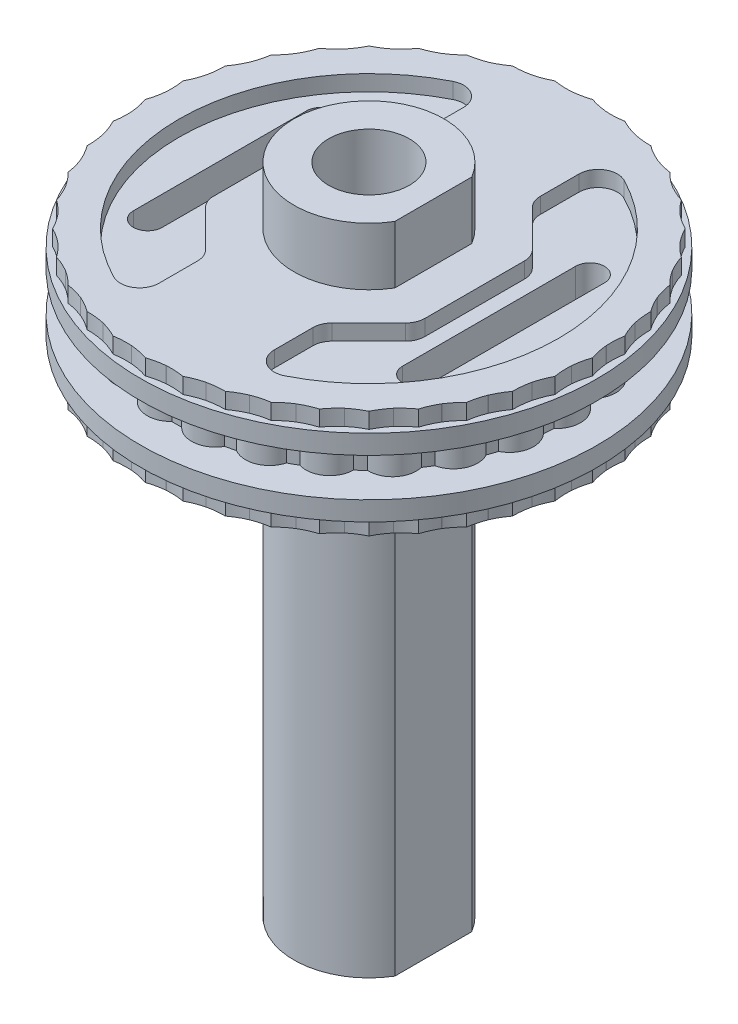
from build123d import *

# Parameters (mm, degrees)
SKETCH1_W                 = 5
SKETCH1_H                 = 1
BOSS_EXTRUDE1_DEPTH       = 1
CIRPATTERN1_COUNT         = 25
BOSS_EXTRUDE2_DEPTH       = 0.4
CIRPATTERN2_COUNT         = 40
MIRROR2_COPY_1_DEPTH      = 0.4
MIRROR2_COPY_2_DEPTH      = 0.4
MIRROR2_COPY_3_DEPTH      = 0.4
MIRROR2_COPY_4_DEPTH      = 0.4
MIRROR2_COPY_5_DEPTH      = 0.4
MIRROR2_COPY_6_DEPTH      = 0.4
MIRROR2_COPY_7_DEPTH      = 0.4
MIRROR2_COPY_8_DEPTH      = 0.4
MIRROR2_COPY_9_DEPTH      = 0.4
MIRROR2_COPY_10_DEPTH     = 0.4
MIRROR2_COPY_11_DEPTH     = 0.4
MIRROR2_COPY_12_DEPTH     = 0.4
MIRROR2_COPY_13_DEPTH     = 0.4
MIRROR2_COPY_14_DEPTH     = 0.4
MIRROR2_COPY_15_DEPTH     = 0.4
MIRROR2_COPY_16_DEPTH     = 0.4
MIRROR2_COPY_17_DEPTH     = 0.4
MIRROR2_COPY_18_DEPTH     = 0.4
MIRROR2_COPY_19_DEPTH     = 0.4
MIRROR2_COPY_20_DEPTH     = 0.4
MIRROR2_COPY_21_DEPTH     = 0.4
MIRROR2_COPY_22_DEPTH     = 0.4
MIRROR2_COPY_23_DEPTH     = 0.4
MIRROR2_COPY_24_DEPTH     = 0.4
MIRROR2_COPY_25_DEPTH     = 0.4
MIRROR2_COPY_26_DEPTH     = 0.4
MIRROR2_COPY_27_DEPTH     = 0.4
MIRROR2_COPY_28_DEPTH     = 0.4
MIRROR2_COPY_29_DEPTH     = 0.4
MIRROR2_COPY_30_DEPTH     = 0.4
MIRROR2_COPY_31_DEPTH     = 0.4
MIRROR2_COPY_32_DEPTH     = 0.4
MIRROR2_COPY_33_DEPTH     = 0.4
MIRROR2_COPY_34_DEPTH     = 0.4
MIRROR2_COPY_35_DEPTH     = 0.4
MIRROR2_COPY_36_DEPTH     = 0.4
MIRROR2_COPY_37_DEPTH     = 0.4
MIRROR2_COPY_38_DEPTH     = 0.4
MIRROR2_COPY_39_DEPTH     = 0.4
BOSS_EXTRUDE4_DEPTH       = 0.01
BOSS_EXTRUDE3_START       = 1.5
BOSS_EXTRUDE3_DEPTH       = 17
CUT_EXTRUDE2_DEPTH        = 17.403157966
CUT_EXTRUDE2_DEPTH_BACK   = 17.403157966
CUT_EXTRUDE3_DEPTH        = 0.41
F_2_0MM_DOWEL_HOLE1_D     = 2.1
F_2_0MM_DOWEL_HOLE1_DEPTH = 7.36909635
F_2_0MM_DOWEL_HOLE1_TIP   = 0.63090365
F_2_0MM_DOWEL_HOLE2_D     = 2.1
F_2_0MM_DOWEL_HOLE2_DEPTH = 7.36909635
F_2_0MM_DOWEL_HOLE2_TIP   = 0.63090365


with BuildPart() as part:
    # Sketch1 → Revolve1 (revolve)
    with BuildSketch(Plane(origin=(0, 0, 0), x_dir=(0, 0, -1), z_dir=(1, 0, 0)), mode=Mode.PRIVATE) as revolve1_sk:
        with Locations((-2.5, 0)):
            Rectangle(SKETCH1_W, SKETCH1_H)
    revolve(revolve1_sk.sketch.rotate(Axis((0, -0.599020678, 0), (0, 1, 0)), 180), axis=Axis((0, -0.599020678, 0), (0, 1, 0)))

    # Sketch2 → Boss-Extrude1 (add)
    with BuildSketch(Plane(origin=(0, 0.5, 0), x_dir=(1, 0, 0), z_dir=(0, 1, 0))):
        with BuildLine():
            ThreePointArc((-0.5, 4.974937186), (0, 5.224937186), (0.5, 4.974937186))
            ThreePointArc((0.5, 4.974937186), (0, 5), (-0.5, 4.974937186))
        make_face()
    boss_extrude1 = extrude(amount=-BOSS_EXTRUDE1_DEPTH)

    # CirPattern1: Boss-Extrude1 ×25 about axis
    cirpattern1_axis = Axis((0, 0, 0), (0, 1, 0))
    for i in range(1, CIRPATTERN1_COUNT):
        add(boss_extrude1.rotate(cirpattern1_axis, i * 360 / CIRPATTERN1_COUNT))

    # Sketch3 → Revolve2 (revolve)
    with BuildSketch(Plane(origin=(0, 0, 0), x_dir=(0, 0, -1), z_dir=(1, 0, 0)), mode=Mode.PRIVATE) as revolve2_sk:
        Polygon((0, 0.5), (-5.938665307, 0.5), (-5.938665307, 1), (-5.738665307, 1), (-5.738665307, 1.4), (0, 1.4), align=None)
    revolve2 = revolve(revolve2_sk.sketch.rotate(Axis((0, 0, 0), (0, 1, 0)), 180), axis=Axis((0, 0, 0), (0, 1, 0)))

    # Sketch4 → Boss-Extrude2 (add)
    with BuildSketch(Plane(origin=(0, 1.4, 0), x_dir=(1, 0, 0), z_dir=(0, 1, 0))):
        with BuildLine():
            Line((0, 5.816841742), (0, 5.738665307))
            ThreePointArc((0, 5.738665307), (0.224059297, 5.734289576), (0.447776903, 5.721169054))
            ThreePointArc((0.447776903, 5.721169054), (0.221141488, 5.756148785), (0, 5.816841742))
        make_face()
        with BuildLine():
            ThreePointArc((-0.447776903, 5.721169054), (-0.224059297, 5.734289576), (0, 5.738665307))
            Line((0, 5.738665307), (0, 5.816841742))
            ThreePointArc((0, 5.816841742), (-0.221141488, 5.756148785), (-0.447776903, 5.721169054))
        make_face()
    boss_extrude2 = extrude(amount=-BOSS_EXTRUDE2_DEPTH)

    # CirPattern2: Boss-Extrude2 ×40 about axis
    cirpattern2_axis = Axis((0, 0, 0), (0, 1, 0))
    for i in range(1, CIRPATTERN2_COUNT):
        add(boss_extrude2.rotate(cirpattern2_axis, i * 360 / CIRPATTERN2_COUNT))

    # Mirror2: Revolve2, Boss-Extrude2 across plane
    add(revolve2.mirror(Plane.ZX))
    add(boss_extrude2.mirror(Plane.ZX))

    # Mirror2 copy 1 sketch → Mirror2 copy 1 (add)
    with BuildSketch(Plane(origin=(0, -1.4, 0), x_dir=(0.9876883405951378, 0, -0.15643446504023087), z_dir=(0, -1, 0))):
        with BuildLine():
            Line((0, -5.816841742), (0, -5.738665307))
            ThreePointArc((0, -5.738665307), (0.224059297, -5.734289576), (0.447776903, -5.721169054))
            ThreePointArc((0.447776903, -5.721169054), (0.221141488, -5.756148785), (0, -5.816841742))
        make_face()
        with BuildLine():
            ThreePointArc((-0.447776903, -5.721169054), (-0.224059297, -5.734289576), (0, -5.738665307))
            Line((0, -5.738665307), (0, -5.816841742))
            ThreePointArc((0, -5.816841742), (-0.221141488, -5.756148785), (-0.447776903, -5.721169054))
        make_face()
    extrude(amount=-MIRROR2_COPY_1_DEPTH)

    # Mirror2 copy 2 sketch → Mirror2 copy 2 (add)
    with BuildSketch(Plane(origin=(0, -1.4, 0), x_dir=(0.9510565162951535, 0, -0.3090169943749474), z_dir=(0, -1, 0))):
        with BuildLine():
            Line((0, -5.816841742), (0, -5.738665307))
            ThreePointArc((0, -5.738665307), (0.224059297, -5.734289576), (0.447776903, -5.721169054))
            ThreePointArc((0.447776903, -5.721169054), (0.221141488, -5.756148785), (0, -5.816841742))
        make_face()
        with BuildLine():
            ThreePointArc((-0.447776903, -5.721169054), (-0.224059297, -5.734289576), (0, -5.738665307))
            Line((0, -5.738665307), (0, -5.816841742))
            ThreePointArc((0, -5.816841742), (-0.221141488, -5.756148785), (-0.447776903, -5.721169054))
        make_face()
    extrude(amount=-MIRROR2_COPY_2_DEPTH)

    # Mirror2 copy 3 sketch → Mirror2 copy 3 (add)
    with BuildSketch(Plane(origin=(0, -1.4, 0), x_dir=(0.8910065241883679, 0, -0.45399049973954675), z_dir=(0, -1, 0))):
        with BuildLine():
            Line((0, -5.816841742), (0, -5.738665307))
            ThreePointArc((0, -5.738665307), (0.224059297, -5.734289576), (0.447776903, -5.721169054))
            ThreePointArc((0.447776903, -5.721169054), (0.221141488, -5.756148785), (0, -5.816841742))
        make_face()
        with BuildLine():
            ThreePointArc((-0.447776903, -5.721169054), (-0.224059297, -5.734289576), (0, -5.738665307))
            Line((0, -5.738665307), (0, -5.816841742))
            ThreePointArc((0, -5.816841742), (-0.221141488, -5.756148785), (-0.447776903, -5.721169054))
        make_face()
    extrude(amount=-MIRROR2_COPY_3_DEPTH)

    # Mirror2 copy 4 sketch → Mirror2 copy 4 (add)
    with BuildSketch(Plane(origin=(0, -1.4, 0), x_dir=(0.8090169943749475, 0, -0.5877852522924731), z_dir=(0, -1, 0))):
        with BuildLine():
            Line((0, -5.816841742), (0, -5.738665307))
            ThreePointArc((0, -5.738665307), (0.224059297, -5.734289576), (0.447776903, -5.721169054))
            ThreePointArc((0.447776903, -5.721169054), (0.221141488, -5.756148785), (0, -5.816841742))
        make_face()
        with BuildLine():
            ThreePointArc((-0.447776903, -5.721169054), (-0.224059297, -5.734289576), (0, -5.738665307))
            Line((0, -5.738665307), (0, -5.816841742))
            ThreePointArc((0, -5.816841742), (-0.221141488, -5.756148785), (-0.447776903, -5.721169054))
        make_face()
    extrude(amount=-MIRROR2_COPY_4_DEPTH)

    # Mirror2 copy 5 sketch → Mirror2 copy 5 (add)
    with BuildSketch(Plane(origin=(0, -1.4, 0), x_dir=(0.7071067811865476, 0, -0.7071067811865475), z_dir=(0, -1, 0))):
        with BuildLine():
            Line((0, -5.816841742), (0, -5.738665307))
            ThreePointArc((0, -5.738665307), (0.224059297, -5.734289576), (0.447776903, -5.721169054))
            ThreePointArc((0.447776903, -5.721169054), (0.221141488, -5.756148785), (0, -5.816841742))
        make_face()
        with BuildLine():
            ThreePointArc((-0.447776903, -5.721169054), (-0.224059297, -5.734289576), (0, -5.738665307))
            Line((0, -5.738665307), (0, -5.816841742))
            ThreePointArc((0, -5.816841742), (-0.221141488, -5.756148785), (-0.447776903, -5.721169054))
        make_face()
    extrude(amount=-MIRROR2_COPY_5_DEPTH)

    # Mirror2 copy 6 sketch → Mirror2 copy 6 (add)
    with BuildSketch(Plane(origin=(0, -1.4, 0), x_dir=(0.5877852522924731, 0, -0.8090169943749475), z_dir=(0, -1, 0))):
        with BuildLine():
            Line((0, -5.816841742), (0, -5.738665307))
            ThreePointArc((0, -5.738665307), (0.224059297, -5.734289576), (0.447776903, -5.721169054))
            ThreePointArc((0.447776903, -5.721169054), (0.221141488, -5.756148785), (0, -5.816841742))
        make_face()
        with BuildLine():
            ThreePointArc((-0.447776903, -5.721169054), (-0.224059297, -5.734289576), (0, -5.738665307))
            Line((0, -5.738665307), (0, -5.816841742))
            ThreePointArc((0, -5.816841742), (-0.221141488, -5.756148785), (-0.447776903, -5.721169054))
        make_face()
    extrude(amount=-MIRROR2_COPY_6_DEPTH)

    # Mirror2 copy 7 sketch → Mirror2 copy 7 (add)
    with BuildSketch(Plane(origin=(0, -1.4, 0), x_dir=(0.4539904997395468, 0, -0.8910065241883678), z_dir=(0, -1, 0))):
        with BuildLine():
            Line((0, -5.816841742), (0, -5.738665307))
            ThreePointArc((0, -5.738665307), (0.224059297, -5.734289576), (0.447776903, -5.721169054))
            ThreePointArc((0.447776903, -5.721169054), (0.221141488, -5.756148785), (0, -5.816841742))
        make_face()
        with BuildLine():
            ThreePointArc((-0.447776903, -5.721169054), (-0.224059297, -5.734289576), (0, -5.738665307))
            Line((0, -5.738665307), (0, -5.816841742))
            ThreePointArc((0, -5.816841742), (-0.221141488, -5.756148785), (-0.447776903, -5.721169054))
        make_face()
    extrude(amount=-MIRROR2_COPY_7_DEPTH)

    # Mirror2 copy 8 sketch → Mirror2 copy 8 (add)
    with BuildSketch(Plane(origin=(0, -1.4, 0), x_dir=(0.30901699437494745, 0, -0.9510565162951535), z_dir=(0, -1, 0))):
        with BuildLine():
            Line((0, -5.816841742), (0, -5.738665307))
            ThreePointArc((0, -5.738665307), (0.224059297, -5.734289576), (0.447776903, -5.721169054))
            ThreePointArc((0.447776903, -5.721169054), (0.221141488, -5.756148785), (0, -5.816841742))
        make_face()
        with BuildLine():
            ThreePointArc((-0.447776903, -5.721169054), (-0.224059297, -5.734289576), (0, -5.738665307))
            Line((0, -5.738665307), (0, -5.816841742))
            ThreePointArc((0, -5.816841742), (-0.221141488, -5.756148785), (-0.447776903, -5.721169054))
        make_face()
    extrude(amount=-MIRROR2_COPY_8_DEPTH)

    # Mirror2 copy 9 sketch → Mirror2 copy 9 (add)
    with BuildSketch(Plane(origin=(0, -1.4, 0), x_dir=(0.15643446504023092, 0, -0.9876883405951378), z_dir=(0, -1, 0))):
        with BuildLine():
            Line((0, -5.816841742), (0, -5.738665307))
            ThreePointArc((0, -5.738665307), (0.224059297, -5.734289576), (0.447776903, -5.721169054))
            ThreePointArc((0.447776903, -5.721169054), (0.221141488, -5.756148785), (0, -5.816841742))
        make_face()
        with BuildLine():
            ThreePointArc((-0.447776903, -5.721169054), (-0.224059297, -5.734289576), (0, -5.738665307))
            Line((0, -5.738665307), (0, -5.816841742))
            ThreePointArc((0, -5.816841742), (-0.221141488, -5.756148785), (-0.447776903, -5.721169054))
        make_face()
    extrude(amount=-MIRROR2_COPY_9_DEPTH)

    # Mirror2 copy 10 sketch → Mirror2 copy 10 (add)
    with BuildSketch(Plane(origin=(0, -1.4, 0), x_dir=(0, 0, -1), z_dir=(0, -1, 0))):
        with BuildLine():
            Line((0, -5.816841742), (0, -5.738665307))
            ThreePointArc((0, -5.738665307), (0.224059297, -5.734289576), (0.447776903, -5.721169054))
            ThreePointArc((0.447776903, -5.721169054), (0.221141488, -5.756148785), (0, -5.816841742))
        make_face()
        with BuildLine():
            ThreePointArc((-0.447776903, -5.721169054), (-0.224059297, -5.734289576), (0, -5.738665307))
            Line((0, -5.738665307), (0, -5.816841742))
            ThreePointArc((0, -5.816841742), (-0.221141488, -5.756148785), (-0.447776903, -5.721169054))
        make_face()
    extrude(amount=-MIRROR2_COPY_10_DEPTH)

    # Mirror2 copy 11 sketch → Mirror2 copy 11 (add)
    with BuildSketch(Plane(origin=(0, -1.4, 0), x_dir=(-0.1564344650402308, 0, -0.9876883405951378), z_dir=(0, -1, 0))):
        with BuildLine():
            Line((0, -5.816841742), (0, -5.738665307))
            ThreePointArc((0, -5.738665307), (0.224059297, -5.734289576), (0.447776903, -5.721169054))
            ThreePointArc((0.447776903, -5.721169054), (0.221141488, -5.756148785), (0, -5.816841742))
        make_face()
        with BuildLine():
            ThreePointArc((-0.447776903, -5.721169054), (-0.224059297, -5.734289576), (0, -5.738665307))
            Line((0, -5.738665307), (0, -5.816841742))
            ThreePointArc((0, -5.816841742), (-0.221141488, -5.756148785), (-0.447776903, -5.721169054))
        make_face()
    extrude(amount=-MIRROR2_COPY_11_DEPTH)

    # Mirror2 copy 12 sketch → Mirror2 copy 12 (add)
    with BuildSketch(Plane(origin=(0, -1.4, 0), x_dir=(-0.30901699437494734, 0, -0.9510565162951536), z_dir=(0, -1, 0))):
        with BuildLine():
            Line((0, -5.816841742), (0, -5.738665307))
            ThreePointArc((0, -5.738665307), (0.224059297, -5.734289576), (0.447776903, -5.721169054))
            ThreePointArc((0.447776903, -5.721169054), (0.221141488, -5.756148785), (0, -5.816841742))
        make_face()
        with BuildLine():
            ThreePointArc((-0.447776903, -5.721169054), (-0.224059297, -5.734289576), (0, -5.738665307))
            Line((0, -5.738665307), (0, -5.816841742))
            ThreePointArc((0, -5.816841742), (-0.221141488, -5.756148785), (-0.447776903, -5.721169054))
        make_face()
    extrude(amount=-MIRROR2_COPY_12_DEPTH)

    # Mirror2 copy 13 sketch → Mirror2 copy 13 (add)
    with BuildSketch(Plane(origin=(0, -1.4, 0), x_dir=(-0.4539904997395467, 0, -0.8910065241883679), z_dir=(0, -1, 0))):
        with BuildLine():
            Line((0, -5.816841742), (0, -5.738665307))
            ThreePointArc((0, -5.738665307), (0.224059297, -5.734289576), (0.447776903, -5.721169054))
            ThreePointArc((0.447776903, -5.721169054), (0.221141488, -5.756148785), (0, -5.816841742))
        make_face()
        with BuildLine():
            ThreePointArc((-0.447776903, -5.721169054), (-0.224059297, -5.734289576), (0, -5.738665307))
            Line((0, -5.738665307), (0, -5.816841742))
            ThreePointArc((0, -5.816841742), (-0.221141488, -5.756148785), (-0.447776903, -5.721169054))
        make_face()
    extrude(amount=-MIRROR2_COPY_13_DEPTH)

    # Mirror2 copy 14 sketch → Mirror2 copy 14 (add)
    with BuildSketch(Plane(origin=(0, -1.4, 0), x_dir=(-0.587785252292473, 0, -0.8090169943749475), z_dir=(0, -1, 0))):
        with BuildLine():
            Line((0, -5.816841742), (0, -5.738665307))
            ThreePointArc((0, -5.738665307), (0.224059297, -5.734289576), (0.447776903, -5.721169054))
            ThreePointArc((0.447776903, -5.721169054), (0.221141488, -5.756148785), (0, -5.816841742))
        make_face()
        with BuildLine():
            ThreePointArc((-0.447776903, -5.721169054), (-0.224059297, -5.734289576), (0, -5.738665307))
            Line((0, -5.738665307), (0, -5.816841742))
            ThreePointArc((0, -5.816841742), (-0.221141488, -5.756148785), (-0.447776903, -5.721169054))
        make_face()
    extrude(amount=-MIRROR2_COPY_14_DEPTH)

    # Mirror2 copy 15 sketch → Mirror2 copy 15 (add)
    with BuildSketch(Plane(origin=(0, -1.4, 0), x_dir=(-0.7071067811865475, 0, -0.7071067811865476), z_dir=(0, -1, 0))):
        with BuildLine():
            Line((0, -5.816841742), (0, -5.738665307))
            ThreePointArc((0, -5.738665307), (0.224059297, -5.734289576), (0.447776903, -5.721169054))
            ThreePointArc((0.447776903, -5.721169054), (0.221141488, -5.756148785), (0, -5.816841742))
        make_face()
        with BuildLine():
            ThreePointArc((-0.447776903, -5.721169054), (-0.224059297, -5.734289576), (0, -5.738665307))
            Line((0, -5.738665307), (0, -5.816841742))
            ThreePointArc((0, -5.816841742), (-0.221141488, -5.756148785), (-0.447776903, -5.721169054))
        make_face()
    extrude(amount=-MIRROR2_COPY_15_DEPTH)

    # Mirror2 copy 16 sketch → Mirror2 copy 16 (add)
    with BuildSketch(Plane(origin=(0, -1.4, 0), x_dir=(-0.8090169943749473, 0, -0.5877852522924732), z_dir=(0, -1, 0))):
        with BuildLine():
            Line((0, -5.816841742), (0, -5.738665307))
            ThreePointArc((0, -5.738665307), (0.224059297, -5.734289576), (0.447776903, -5.721169054))
            ThreePointArc((0.447776903, -5.721169054), (0.221141488, -5.756148785), (0, -5.816841742))
        make_face()
        with BuildLine():
            ThreePointArc((-0.447776903, -5.721169054), (-0.224059297, -5.734289576), (0, -5.738665307))
            Line((0, -5.738665307), (0, -5.816841742))
            ThreePointArc((0, -5.816841742), (-0.221141488, -5.756148785), (-0.447776903, -5.721169054))
        make_face()
    extrude(amount=-MIRROR2_COPY_16_DEPTH)

    # Mirror2 copy 17 sketch → Mirror2 copy 17 (add)
    with BuildSketch(Plane(origin=(0, -1.4, 0), x_dir=(-0.8910065241883678, 0, -0.45399049973954686), z_dir=(0, -1, 0))):
        with BuildLine():
            Line((0, -5.816841742), (0, -5.738665307))
            ThreePointArc((0, -5.738665307), (0.224059297, -5.734289576), (0.447776903, -5.721169054))
            ThreePointArc((0.447776903, -5.721169054), (0.221141488, -5.756148785), (0, -5.816841742))
        make_face()
        with BuildLine():
            ThreePointArc((-0.447776903, -5.721169054), (-0.224059297, -5.734289576), (0, -5.738665307))
            Line((0, -5.738665307), (0, -5.816841742))
            ThreePointArc((0, -5.816841742), (-0.221141488, -5.756148785), (-0.447776903, -5.721169054))
        make_face()
    extrude(amount=-MIRROR2_COPY_17_DEPTH)

    # Mirror2 copy 18 sketch → Mirror2 copy 18 (add)
    with BuildSketch(Plane(origin=(0, -1.4, 0), x_dir=(-0.9510565162951535, 0, -0.3090169943749475), z_dir=(0, -1, 0))):
        with BuildLine():
            Line((0, -5.816841742), (0, -5.738665307))
            ThreePointArc((0, -5.738665307), (0.224059297, -5.734289576), (0.447776903, -5.721169054))
            ThreePointArc((0.447776903, -5.721169054), (0.221141488, -5.756148785), (0, -5.816841742))
        make_face()
        with BuildLine():
            ThreePointArc((-0.447776903, -5.721169054), (-0.224059297, -5.734289576), (0, -5.738665307))
            Line((0, -5.738665307), (0, -5.816841742))
            ThreePointArc((0, -5.816841742), (-0.221141488, -5.756148785), (-0.447776903, -5.721169054))
        make_face()
    extrude(amount=-MIRROR2_COPY_18_DEPTH)

    # Mirror2 copy 19 sketch → Mirror2 copy 19 (add)
    with BuildSketch(Plane(origin=(0, -1.4, 0), x_dir=(-0.9876883405951377, 0, -0.15643446504023098), z_dir=(0, -1, 0))):
        with BuildLine():
            Line((0, -5.816841742), (0, -5.738665307))
            ThreePointArc((0, -5.738665307), (0.224059297, -5.734289576), (0.447776903, -5.721169054))
            ThreePointArc((0.447776903, -5.721169054), (0.221141488, -5.756148785), (0, -5.816841742))
        make_face()
        with BuildLine():
            ThreePointArc((-0.447776903, -5.721169054), (-0.224059297, -5.734289576), (0, -5.738665307))
            Line((0, -5.738665307), (0, -5.816841742))
            ThreePointArc((0, -5.816841742), (-0.221141488, -5.756148785), (-0.447776903, -5.721169054))
        make_face()
    extrude(amount=-MIRROR2_COPY_19_DEPTH)

    # Mirror2 copy 20 sketch → Mirror2 copy 20 (add)
    with BuildSketch(Plane(origin=(0, -1.4, 0), x_dir=(-1, 0, 0), z_dir=(0, -1, 0))):
        with BuildLine():
            Line((0, -5.816841742), (0, -5.738665307))
            ThreePointArc((0, -5.738665307), (0.224059297, -5.734289576), (0.447776903, -5.721169054))
            ThreePointArc((0.447776903, -5.721169054), (0.221141488, -5.756148785), (0, -5.816841742))
        make_face()
        with BuildLine():
            ThreePointArc((-0.447776903, -5.721169054), (-0.224059297, -5.734289576), (0, -5.738665307))
            Line((0, -5.738665307), (0, -5.816841742))
            ThreePointArc((0, -5.816841742), (-0.221141488, -5.756148785), (-0.447776903, -5.721169054))
        make_face()
    extrude(amount=-MIRROR2_COPY_20_DEPTH)

    # Mirror2 copy 21 sketch → Mirror2 copy 21 (add)
    with BuildSketch(Plane(origin=(0, -1.4, 0), x_dir=(-0.9876883405951378, 0, 0.15643446504023073), z_dir=(0, -1, 0))):
        with BuildLine():
            Line((0, -5.816841742), (0, -5.738665307))
            ThreePointArc((0, -5.738665307), (0.224059297, -5.734289576), (0.447776903, -5.721169054))
            ThreePointArc((0.447776903, -5.721169054), (0.221141488, -5.756148785), (0, -5.816841742))
        make_face()
        with BuildLine():
            ThreePointArc((-0.447776903, -5.721169054), (-0.224059297, -5.734289576), (0, -5.738665307))
            Line((0, -5.738665307), (0, -5.816841742))
            ThreePointArc((0, -5.816841742), (-0.221141488, -5.756148785), (-0.447776903, -5.721169054))
        make_face()
    extrude(amount=-MIRROR2_COPY_21_DEPTH)

    # Mirror2 copy 22 sketch → Mirror2 copy 22 (add)
    with BuildSketch(Plane(origin=(0, -1.4, 0), x_dir=(-0.9510565162951536, 0, 0.3090169943749473), z_dir=(0, -1, 0))):
        with BuildLine():
            Line((0, -5.816841742), (0, -5.738665307))
            ThreePointArc((0, -5.738665307), (0.224059297, -5.734289576), (0.447776903, -5.721169054))
            ThreePointArc((0.447776903, -5.721169054), (0.221141488, -5.756148785), (0, -5.816841742))
        make_face()
        with BuildLine():
            ThreePointArc((-0.447776903, -5.721169054), (-0.224059297, -5.734289576), (0, -5.738665307))
            Line((0, -5.738665307), (0, -5.816841742))
            ThreePointArc((0, -5.816841742), (-0.221141488, -5.756148785), (-0.447776903, -5.721169054))
        make_face()
    extrude(amount=-MIRROR2_COPY_22_DEPTH)

    # Mirror2 copy 23 sketch → Mirror2 copy 23 (add)
    with BuildSketch(Plane(origin=(0, -1.4, 0), x_dir=(-0.8910065241883679, 0, 0.4539904997395467), z_dir=(0, -1, 0))):
        with BuildLine():
            Line((0, -5.816841742), (0, -5.738665307))
            ThreePointArc((0, -5.738665307), (0.224059297, -5.734289576), (0.447776903, -5.721169054))
            ThreePointArc((0.447776903, -5.721169054), (0.221141488, -5.756148785), (0, -5.816841742))
        make_face()
        with BuildLine():
            ThreePointArc((-0.447776903, -5.721169054), (-0.224059297, -5.734289576), (0, -5.738665307))
            Line((0, -5.738665307), (0, -5.816841742))
            ThreePointArc((0, -5.816841742), (-0.221141488, -5.756148785), (-0.447776903, -5.721169054))
        make_face()
    extrude(amount=-MIRROR2_COPY_23_DEPTH)

    # Mirror2 copy 24 sketch → Mirror2 copy 24 (add)
    with BuildSketch(Plane(origin=(0, -1.4, 0), x_dir=(-0.8090169943749476, 0, 0.587785252292473), z_dir=(0, -1, 0))):
        with BuildLine():
            Line((0, -5.816841742), (0, -5.738665307))
            ThreePointArc((0, -5.738665307), (0.224059297, -5.734289576), (0.447776903, -5.721169054))
            ThreePointArc((0.447776903, -5.721169054), (0.221141488, -5.756148785), (0, -5.816841742))
        make_face()
        with BuildLine():
            ThreePointArc((-0.447776903, -5.721169054), (-0.224059297, -5.734289576), (0, -5.738665307))
            Line((0, -5.738665307), (0, -5.816841742))
            ThreePointArc((0, -5.816841742), (-0.221141488, -5.756148785), (-0.447776903, -5.721169054))
        make_face()
    extrude(amount=-MIRROR2_COPY_24_DEPTH)

    # Mirror2 copy 25 sketch → Mirror2 copy 25 (add)
    with BuildSketch(Plane(origin=(0, -1.4, 0), x_dir=(-0.7071067811865477, 0, 0.7071067811865475), z_dir=(0, -1, 0))):
        with BuildLine():
            Line((0, -5.816841742), (0, -5.738665307))
            ThreePointArc((0, -5.738665307), (0.224059297, -5.734289576), (0.447776903, -5.721169054))
            ThreePointArc((0.447776903, -5.721169054), (0.221141488, -5.756148785), (0, -5.816841742))
        make_face()
        with BuildLine():
            ThreePointArc((-0.447776903, -5.721169054), (-0.224059297, -5.734289576), (0, -5.738665307))
            Line((0, -5.738665307), (0, -5.816841742))
            ThreePointArc((0, -5.816841742), (-0.221141488, -5.756148785), (-0.447776903, -5.721169054))
        make_face()
    extrude(amount=-MIRROR2_COPY_25_DEPTH)

    # Mirror2 copy 26 sketch → Mirror2 copy 26 (add)
    with BuildSketch(Plane(origin=(0, -1.4, 0), x_dir=(-0.5877852522924732, 0, 0.8090169943749473), z_dir=(0, -1, 0))):
        with BuildLine():
            Line((0, -5.816841742), (0, -5.738665307))
            ThreePointArc((0, -5.738665307), (0.224059297, -5.734289576), (0.447776903, -5.721169054))
            ThreePointArc((0.447776903, -5.721169054), (0.221141488, -5.756148785), (0, -5.816841742))
        make_face()
        with BuildLine():
            ThreePointArc((-0.447776903, -5.721169054), (-0.224059297, -5.734289576), (0, -5.738665307))
            Line((0, -5.738665307), (0, -5.816841742))
            ThreePointArc((0, -5.816841742), (-0.221141488, -5.756148785), (-0.447776903, -5.721169054))
        make_face()
    extrude(amount=-MIRROR2_COPY_26_DEPTH)

    # Mirror2 copy 27 sketch → Mirror2 copy 27 (add)
    with BuildSketch(Plane(origin=(0, -1.4, 0), x_dir=(-0.4539904997395469, 0, 0.8910065241883678), z_dir=(0, -1, 0))):
        with BuildLine():
            Line((0, -5.816841742), (0, -5.738665307))
            ThreePointArc((0, -5.738665307), (0.224059297, -5.734289576), (0.447776903, -5.721169054))
            ThreePointArc((0.447776903, -5.721169054), (0.221141488, -5.756148785), (0, -5.816841742))
        make_face()
        with BuildLine():
            ThreePointArc((-0.447776903, -5.721169054), (-0.224059297, -5.734289576), (0, -5.738665307))
            Line((0, -5.738665307), (0, -5.816841742))
            ThreePointArc((0, -5.816841742), (-0.221141488, -5.756148785), (-0.447776903, -5.721169054))
        make_face()
    extrude(amount=-MIRROR2_COPY_27_DEPTH)

    # Mirror2 copy 28 sketch → Mirror2 copy 28 (add)
    with BuildSketch(Plane(origin=(0, -1.4, 0), x_dir=(-0.30901699437494756, 0, 0.9510565162951535), z_dir=(0, -1, 0))):
        with BuildLine():
            Line((0, -5.816841742), (0, -5.738665307))
            ThreePointArc((0, -5.738665307), (0.224059297, -5.734289576), (0.447776903, -5.721169054))
            ThreePointArc((0.447776903, -5.721169054), (0.221141488, -5.756148785), (0, -5.816841742))
        make_face()
        with BuildLine():
            ThreePointArc((-0.447776903, -5.721169054), (-0.224059297, -5.734289576), (0, -5.738665307))
            Line((0, -5.738665307), (0, -5.816841742))
            ThreePointArc((0, -5.816841742), (-0.221141488, -5.756148785), (-0.447776903, -5.721169054))
        make_face()
    extrude(amount=-MIRROR2_COPY_28_DEPTH)

    # Mirror2 copy 29 sketch → Mirror2 copy 29 (add)
    with BuildSketch(Plane(origin=(0, -1.4, 0), x_dir=(-0.15643446504023104, 0, 0.9876883405951377), z_dir=(0, -1, 0))):
        with BuildLine():
            Line((0, -5.816841742), (0, -5.738665307))
            ThreePointArc((0, -5.738665307), (0.224059297, -5.734289576), (0.447776903, -5.721169054))
            ThreePointArc((0.447776903, -5.721169054), (0.221141488, -5.756148785), (0, -5.816841742))
        make_face()
        with BuildLine():
            ThreePointArc((-0.447776903, -5.721169054), (-0.224059297, -5.734289576), (0, -5.738665307))
            Line((0, -5.738665307), (0, -5.816841742))
            ThreePointArc((0, -5.816841742), (-0.221141488, -5.756148785), (-0.447776903, -5.721169054))
        make_face()
    extrude(amount=-MIRROR2_COPY_29_DEPTH)

    # Mirror2 copy 30 sketch → Mirror2 copy 30 (add)
    with BuildSketch(Plane(origin=(0, -1.4, 0), x_dir=(0, 0, 1), z_dir=(0, -1, 0))):
        with BuildLine():
            Line((0, -5.816841742), (0, -5.738665307))
            ThreePointArc((0, -5.738665307), (0.224059297, -5.734289576), (0.447776903, -5.721169054))
            ThreePointArc((0.447776903, -5.721169054), (0.221141488, -5.756148785), (0, -5.816841742))
        make_face()
        with BuildLine():
            ThreePointArc((-0.447776903, -5.721169054), (-0.224059297, -5.734289576), (0, -5.738665307))
            Line((0, -5.738665307), (0, -5.816841742))
            ThreePointArc((0, -5.816841742), (-0.221141488, -5.756148785), (-0.447776903, -5.721169054))
        make_face()
    extrude(amount=-MIRROR2_COPY_30_DEPTH)

    # Mirror2 copy 31 sketch → Mirror2 copy 31 (add)
    with BuildSketch(Plane(origin=(0, -1.4, 0), x_dir=(0.15643446504023067, 0, 0.9876883405951378), z_dir=(0, -1, 0))):
        with BuildLine():
            Line((0, -5.816841742), (0, -5.738665307))
            ThreePointArc((0, -5.738665307), (0.224059297, -5.734289576), (0.447776903, -5.721169054))
            ThreePointArc((0.447776903, -5.721169054), (0.221141488, -5.756148785), (0, -5.816841742))
        make_face()
        with BuildLine():
            ThreePointArc((-0.447776903, -5.721169054), (-0.224059297, -5.734289576), (0, -5.738665307))
            Line((0, -5.738665307), (0, -5.816841742))
            ThreePointArc((0, -5.816841742), (-0.221141488, -5.756148785), (-0.447776903, -5.721169054))
        make_face()
    extrude(amount=-MIRROR2_COPY_31_DEPTH)

    # Mirror2 copy 32 sketch → Mirror2 copy 32 (add)
    with BuildSketch(Plane(origin=(0, -1.4, 0), x_dir=(0.30901699437494723, 0, 0.9510565162951536), z_dir=(0, -1, 0))):
        with BuildLine():
            Line((0, -5.816841742), (0, -5.738665307))
            ThreePointArc((0, -5.738665307), (0.224059297, -5.734289576), (0.447776903, -5.721169054))
            ThreePointArc((0.447776903, -5.721169054), (0.221141488, -5.756148785), (0, -5.816841742))
        make_face()
        with BuildLine():
            ThreePointArc((-0.447776903, -5.721169054), (-0.224059297, -5.734289576), (0, -5.738665307))
            Line((0, -5.738665307), (0, -5.816841742))
            ThreePointArc((0, -5.816841742), (-0.221141488, -5.756148785), (-0.447776903, -5.721169054))
        make_face()
    extrude(amount=-MIRROR2_COPY_32_DEPTH)

    # Mirror2 copy 33 sketch → Mirror2 copy 33 (add)
    with BuildSketch(Plane(origin=(0, -1.4, 0), x_dir=(0.45399049973954664, 0, 0.891006524188368), z_dir=(0, -1, 0))):
        with BuildLine():
            Line((0, -5.816841742), (0, -5.738665307))
            ThreePointArc((0, -5.738665307), (0.224059297, -5.734289576), (0.447776903, -5.721169054))
            ThreePointArc((0.447776903, -5.721169054), (0.221141488, -5.756148785), (0, -5.816841742))
        make_face()
        with BuildLine():
            ThreePointArc((-0.447776903, -5.721169054), (-0.224059297, -5.734289576), (0, -5.738665307))
            Line((0, -5.738665307), (0, -5.816841742))
            ThreePointArc((0, -5.816841742), (-0.221141488, -5.756148785), (-0.447776903, -5.721169054))
        make_face()
    extrude(amount=-MIRROR2_COPY_33_DEPTH)

    # Mirror2 copy 34 sketch → Mirror2 copy 34 (add)
    with BuildSketch(Plane(origin=(0, -1.4, 0), x_dir=(0.5877852522924729, 0, 0.8090169943749476), z_dir=(0, -1, 0))):
        with BuildLine():
            Line((0, -5.816841742), (0, -5.738665307))
            ThreePointArc((0, -5.738665307), (0.224059297, -5.734289576), (0.447776903, -5.721169054))
            ThreePointArc((0.447776903, -5.721169054), (0.221141488, -5.756148785), (0, -5.816841742))
        make_face()
        with BuildLine():
            ThreePointArc((-0.447776903, -5.721169054), (-0.224059297, -5.734289576), (0, -5.738665307))
            Line((0, -5.738665307), (0, -5.816841742))
            ThreePointArc((0, -5.816841742), (-0.221141488, -5.756148785), (-0.447776903, -5.721169054))
        make_face()
    extrude(amount=-MIRROR2_COPY_34_DEPTH)

    # Mirror2 copy 35 sketch → Mirror2 copy 35 (add)
    with BuildSketch(Plane(origin=(0, -1.4, 0), x_dir=(0.7071067811865474, 0, 0.7071067811865477), z_dir=(0, -1, 0))):
        with BuildLine():
            Line((0, -5.816841742), (0, -5.738665307))
            ThreePointArc((0, -5.738665307), (0.224059297, -5.734289576), (0.447776903, -5.721169054))
            ThreePointArc((0.447776903, -5.721169054), (0.221141488, -5.756148785), (0, -5.816841742))
        make_face()
        with BuildLine():
            ThreePointArc((-0.447776903, -5.721169054), (-0.224059297, -5.734289576), (0, -5.738665307))
            Line((0, -5.738665307), (0, -5.816841742))
            ThreePointArc((0, -5.816841742), (-0.221141488, -5.756148785), (-0.447776903, -5.721169054))
        make_face()
    extrude(amount=-MIRROR2_COPY_35_DEPTH)

    # Mirror2 copy 36 sketch → Mirror2 copy 36 (add)
    with BuildSketch(Plane(origin=(0, -1.4, 0), x_dir=(0.8090169943749473, 0, 0.5877852522924734), z_dir=(0, -1, 0))):
        with BuildLine():
            Line((0, -5.816841742), (0, -5.738665307))
            ThreePointArc((0, -5.738665307), (0.224059297, -5.734289576), (0.447776903, -5.721169054))
            ThreePointArc((0.447776903, -5.721169054), (0.221141488, -5.756148785), (0, -5.816841742))
        make_face()
        with BuildLine():
            ThreePointArc((-0.447776903, -5.721169054), (-0.224059297, -5.734289576), (0, -5.738665307))
            Line((0, -5.738665307), (0, -5.816841742))
            ThreePointArc((0, -5.816841742), (-0.221141488, -5.756148785), (-0.447776903, -5.721169054))
        make_face()
    extrude(amount=-MIRROR2_COPY_36_DEPTH)

    # Mirror2 copy 37 sketch → Mirror2 copy 37 (add)
    with BuildSketch(Plane(origin=(0, -1.4, 0), x_dir=(0.8910065241883678, 0, 0.45399049973954697), z_dir=(0, -1, 0))):
        with BuildLine():
            Line((0, -5.816841742), (0, -5.738665307))
            ThreePointArc((0, -5.738665307), (0.224059297, -5.734289576), (0.447776903, -5.721169054))
            ThreePointArc((0.447776903, -5.721169054), (0.221141488, -5.756148785), (0, -5.816841742))
        make_face()
        with BuildLine():
            ThreePointArc((-0.447776903, -5.721169054), (-0.224059297, -5.734289576), (0, -5.738665307))
            Line((0, -5.738665307), (0, -5.816841742))
            ThreePointArc((0, -5.816841742), (-0.221141488, -5.756148785), (-0.447776903, -5.721169054))
        make_face()
    extrude(amount=-MIRROR2_COPY_37_DEPTH)

    # Mirror2 copy 38 sketch → Mirror2 copy 38 (add)
    with BuildSketch(Plane(origin=(0, -1.4, 0), x_dir=(0.9510565162951535, 0, 0.3090169943749476), z_dir=(0, -1, 0))):
        with BuildLine():
            Line((0, -5.816841742), (0, -5.738665307))
            ThreePointArc((0, -5.738665307), (0.224059297, -5.734289576), (0.447776903, -5.721169054))
            ThreePointArc((0.447776903, -5.721169054), (0.221141488, -5.756148785), (0, -5.816841742))
        make_face()
        with BuildLine():
            ThreePointArc((-0.447776903, -5.721169054), (-0.224059297, -5.734289576), (0, -5.738665307))
            Line((0, -5.738665307), (0, -5.816841742))
            ThreePointArc((0, -5.816841742), (-0.221141488, -5.756148785), (-0.447776903, -5.721169054))
        make_face()
    extrude(amount=-MIRROR2_COPY_38_DEPTH)

    # Mirror2 copy 39 sketch → Mirror2 copy 39 (add)
    with BuildSketch(Plane(origin=(0, -1.4, 0), x_dir=(0.9876883405951377, 0, 0.15643446504023112), z_dir=(0, -1, 0))):
        with BuildLine():
            Line((0, -5.816841742), (0, -5.738665307))
            ThreePointArc((0, -5.738665307), (0.224059297, -5.734289576), (0.447776903, -5.721169054))
            ThreePointArc((0.447776903, -5.721169054), (0.221141488, -5.756148785), (0, -5.816841742))
        make_face()
        with BuildLine():
            ThreePointArc((-0.447776903, -5.721169054), (-0.224059297, -5.734289576), (0, -5.738665307))
            Line((0, -5.738665307), (0, -5.816841742))
            ThreePointArc((0, -5.816841742), (-0.221141488, -5.756148785), (-0.447776903, -5.721169054))
        make_face()
    extrude(amount=-MIRROR2_COPY_39_DEPTH)

    # Sketch16 → Boss-Extrude4 (add)
    with BuildSketch(Plane(origin=(0, 1.4, 0), x_dir=(1, 0, 0), z_dir=(0, 1, 0))):
        with BuildLine():
            Line((-1.337252047, 5.580684229), (-1.342077324, 5.579525783))
            ThreePointArc((-1.342077324, 5.579525783), (-1.568429743, 5.542759289), (-1.797502952, 5.532145243))
            ThreePointArc((-1.797502952, 5.532145243), (-1.98906585, 5.406086333), (-2.193799607, 5.302784437))
            Line((-2.193799607, 5.302784437), (-2.198384256, 5.300885413))
            ThreePointArc((-2.198384256, 5.300885413), (-2.416198355, 5.229162257), (-2.640790889, 5.182843942))
            ThreePointArc((-2.640790889, 5.182843942), (-2.810275372, 5.028369987), (-2.99632854, 4.894312494))
            Line((-2.99632854, 4.894312494), (-3.000559672, 4.891719653))
            ThreePointArc((-3.000559672, 4.891719653), (-3.204472144, 4.786805895), (-3.419053791, 4.705923823))
            ThreePointArc((-3.419053791, 4.705923823), (-3.562286588, 4.526838484), (-3.72507792, 4.365326333))
            Line((-3.72507792, 4.365326333), (-3.72885135, 4.362103519))
            ThreePointArc((-3.72885135, 4.362103519), (-3.913841194, 4.226582486), (-4.113128241, 4.113128241))
            ThreePointArc((-4.113128241, 4.113128241), (-4.226582486, 3.913841194), (-4.362103519, 3.72885135))
            Line((-4.362103519, 3.72885135), (-4.365326333, 3.72507792))
            ThreePointArc((-4.365326333, 3.72507792), (-4.526838484, 3.562286588), (-4.705923823, 3.419053791))
            ThreePointArc((-4.705923823, 3.419053791), (-4.786805895, 3.204472144), (-4.891719653, 3.000559672))
            Line((-4.891719653, 3.000559672), (-4.894312494, 2.99632854))
            ThreePointArc((-4.894312494, 2.99632854), (-5.028369987, 2.810275372), (-5.182843942, 2.640790889))
            ThreePointArc((-5.182843942, 2.640790889), (-5.229162257, 2.416198355), (-5.300885413, 2.198384256))
            Line((-5.300885413, 2.198384256), (-5.302784437, 2.193799607))
            ThreePointArc((-5.302784437, 2.193799607), (-5.406086333, 1.98906585), (-5.532145243, 1.797502952))
            ThreePointArc((-5.532145243, 1.797502952), (-5.542759289, 1.568429743), (-5.579525783, 1.342077324))
            Line((-5.579525783, 1.342077324), (-5.580684229, 1.337252047))
            ThreePointArc((-5.580684229, 1.337252047), (-5.650686892, 1.118878925), (-5.745226768, 0.909954526))
            ThreePointArc((-5.745226768, 0.909954526), (-5.719875192, 0.682041186), (-5.72077971, 0.452723994))
            Line((-5.72077971, 0.452723994), (-5.721169054, 0.447776903))
            ThreePointArc((-5.721169054, 0.447776903), (-5.756148785, 0.221141488), (-5.816841742, 0))
            ThreePointArc((-5.816841742, 0), (-5.756148785, -0.221141488), (-5.721169054, -0.447776903))
            Line((-5.721169054, -0.447776903), (-5.72077971, -0.452723994))
            ThreePointArc((-5.72077971, -0.452723994), (-5.719875192, -0.682041186), (-5.745226768, -0.909954526))
            ThreePointArc((-5.745226768, -0.909954526), (-5.650686892, -1.118878925), (-5.580684229, -1.337252047))
            Line((-5.580684229, -1.337252047), (-5.579525783, -1.342077324))
            ThreePointArc((-5.579525783, -1.342077324), (-5.542759289, -1.568429743), (-5.532145243, -1.797502952))
            ThreePointArc((-5.532145243, -1.797502952), (-5.406086333, -1.98906585), (-5.302784437, -2.193799607))
            Line((-5.302784437, -2.193799607), (-5.300885413, -2.198384256))
            ThreePointArc((-5.300885413, -2.198384256), (-5.229162257, -2.416198355), (-5.182843942, -2.640790889))
            ThreePointArc((-5.182843942, -2.640790889), (-5.028369987, -2.810275372), (-4.894312494, -2.99632854))
            Line((-4.894312494, -2.99632854), (-4.891719653, -3.000559672))
            ThreePointArc((-4.891719653, -3.000559672), (-4.786805895, -3.204472144), (-4.705923823, -3.419053791))
            ThreePointArc((-4.705923823, -3.419053791), (-4.526838484, -3.562286588), (-4.365326333, -3.72507792))
            Line((-4.365326333, -3.72507792), (-4.362103519, -3.72885135))
            ThreePointArc((-4.362103519, -3.72885135), (-4.226582486, -3.913841194), (-4.113128241, -4.113128241))
            ThreePointArc((-4.113128241, -4.113128241), (-3.913841194, -4.226582486), (-3.72885135, -4.362103519))
            Line((-3.72885135, -4.362103519), (-3.72507792, -4.365326333))
            ThreePointArc((-3.72507792, -4.365326333), (-3.562286588, -4.526838484), (-3.419053791, -4.705923823))
            ThreePointArc((-3.419053791, -4.705923823), (-3.204472144, -4.786805895), (-3.000559672, -4.891719653))
            Line((-3.000559672, -4.891719653), (-2.99632854, -4.894312494))
            ThreePointArc((-2.99632854, -4.894312494), (-2.810275372, -5.028369987), (-2.640790889, -5.182843942))
            ThreePointArc((-2.640790889, -5.182843942), (-2.416198355, -5.229162257), (-2.198384256, -5.300885413))
            Line((-2.198384256, -5.300885413), (-2.193799607, -5.302784437))
            ThreePointArc((-2.193799607, -5.302784437), (-1.98906585, -5.406086333), (-1.797502952, -5.532145243))
            ThreePointArc((-1.797502952, -5.532145243), (-1.568429743, -5.542759289), (-1.342077324, -5.579525783))
            Line((-1.342077324, -5.579525783), (-1.337252047, -5.580684229))
            ThreePointArc((-1.337252047, -5.580684229), (-1.118878925, -5.650686892), (-0.909954526, -5.745226768))
            ThreePointArc((-0.909954526, -5.745226768), (-0.682041186, -5.719875192), (-0.452723994, -5.72077971))
            Line((-0.452723994, -5.72077971), (-0.447776903, -5.721169054))
            ThreePointArc((-0.447776903, -5.721169054), (-0.221141488, -5.756148785), (0, -5.816841742))
            ThreePointArc((0, -5.816841742), (0.221141488, -5.756148785), (0.447776903, -5.721169054))
            Line((0.447776903, -5.721169054), (0.452723994, -5.72077971))
            ThreePointArc((0.452723994, -5.72077971), (0.682041186, -5.719875192), (0.909954526, -5.745226768))
            ThreePointArc((0.909954526, -5.745226768), (1.118878925, -5.650686892), (1.337252047, -5.580684229))
            Line((1.337252047, -5.580684229), (1.342077324, -5.579525783))
            ThreePointArc((1.342077324, -5.579525783), (1.568429743, -5.542759289), (1.797502952, -5.532145243))
            ThreePointArc((1.797502952, -5.532145243), (1.98906585, -5.406086333), (2.193799607, -5.302784437))
            Line((2.193799607, -5.302784437), (2.198384256, -5.300885413))
            ThreePointArc((2.198384256, -5.300885413), (2.416198355, -5.229162257), (2.640790889, -5.182843942))
            ThreePointArc((2.640790889, -5.182843942), (2.810275372, -5.028369987), (2.99632854, -4.894312494))
            Line((2.99632854, -4.894312494), (3.000559672, -4.891719653))
            ThreePointArc((3.000559672, -4.891719653), (3.204472144, -4.786805895), (3.419053791, -4.705923823))
            ThreePointArc((3.419053791, -4.705923823), (3.562286588, -4.526838484), (3.72507792, -4.365326333))
            Line((3.72507792, -4.365326333), (3.72885135, -4.362103519))
            ThreePointArc((3.72885135, -4.362103519), (3.913841194, -4.226582486), (4.113128241, -4.113128241))
            ThreePointArc((4.113128241, -4.113128241), (4.226582486, -3.913841194), (4.362103519, -3.72885135))
            Line((4.362103519, -3.72885135), (4.365326333, -3.72507792))
            ThreePointArc((4.365326333, -3.72507792), (4.526838484, -3.562286588), (4.705923823, -3.419053791))
            ThreePointArc((4.705923823, -3.419053791), (4.786805895, -3.204472144), (4.891719653, -3.000559672))
            Line((4.891719653, -3.000559672), (4.894312494, -2.99632854))
            ThreePointArc((4.894312494, -2.99632854), (5.028369987, -2.810275372), (5.182843942, -2.640790889))
            ThreePointArc((5.182843942, -2.640790889), (5.229162257, -2.416198355), (5.300885413, -2.198384256))
            Line((5.300885413, -2.198384256), (5.302784437, -2.193799607))
            ThreePointArc((5.302784437, -2.193799607), (5.406086333, -1.98906585), (5.532145243, -1.797502952))
            ThreePointArc((5.532145243, -1.797502952), (5.542759289, -1.568429743), (5.579525783, -1.342077324))
            Line((5.579525783, -1.342077324), (5.580684229, -1.337252047))
            ThreePointArc((5.580684229, -1.337252047), (5.650686892, -1.118878925), (5.745226768, -0.909954526))
            ThreePointArc((5.745226768, -0.909954526), (5.719875192, -0.682041186), (5.72077971, -0.452723994))
            Line((5.72077971, -0.452723994), (5.721169054, -0.447776903))
            ThreePointArc((5.721169054, -0.447776903), (5.756148785, -0.221141488), (5.816841742, 0))
            ThreePointArc((5.816841742, 0), (5.756148785, 0.221141488), (5.721169054, 0.447776903))
            Line((5.721169054, 0.447776903), (5.72077971, 0.452723994))
            ThreePointArc((5.72077971, 0.452723994), (5.719875192, 0.682041186), (5.745226768, 0.909954526))
            ThreePointArc((5.745226768, 0.909954526), (5.650686892, 1.118878925), (5.580684229, 1.337252047))
            Line((5.580684229, 1.337252047), (5.579525783, 1.342077324))
            ThreePointArc((5.579525783, 1.342077324), (5.542759289, 1.568429743), (5.532145243, 1.797502952))
            ThreePointArc((5.532145243, 1.797502952), (5.406086333, 1.98906585), (5.302784437, 2.193799607))
            Line((5.302784437, 2.193799607), (5.300885413, 2.198384256))
            ThreePointArc((5.300885413, 2.198384256), (5.229162257, 2.416198355), (5.182843942, 2.640790889))
            ThreePointArc((5.182843942, 2.640790889), (5.028369987, 2.810275372), (4.894312494, 2.99632854))
            Line((4.894312494, 2.99632854), (4.891719653, 3.000559672))
            ThreePointArc((4.891719653, 3.000559672), (4.786805895, 3.204472144), (4.705923823, 3.419053791))
            ThreePointArc((4.705923823, 3.419053791), (4.526838484, 3.562286588), (4.365326333, 3.72507792))
            Line((4.365326333, 3.72507792), (4.362103519, 3.72885135))
            ThreePointArc((4.362103519, 3.72885135), (4.226582486, 3.913841194), (4.113128241, 4.113128241))
            ThreePointArc((4.113128241, 4.113128241), (3.913841194, 4.226582486), (3.72885135, 4.362103519))
            Line((3.72885135, 4.362103519), (3.72507792, 4.365326333))
            ThreePointArc((3.72507792, 4.365326333), (3.562286588, 4.526838484), (3.419053791, 4.705923823))
            ThreePointArc((3.419053791, 4.705923823), (3.204472144, 4.786805895), (3.000559672, 4.891719653))
            Line((3.000559672, 4.891719653), (2.99632854, 4.894312494))
            ThreePointArc((2.99632854, 4.894312494), (2.810275372, 5.028369987), (2.640790889, 5.182843942))
            ThreePointArc((2.640790889, 5.182843942), (2.416198355, 5.229162257), (2.198384256, 5.300885413))
            Line((2.198384256, 5.300885413), (2.193799607, 5.302784437))
            ThreePointArc((2.193799607, 5.302784437), (1.98906585, 5.406086333), (1.797502952, 5.532145243))
            ThreePointArc((1.797502952, 5.532145243), (1.568429743, 5.542759289), (1.342077324, 5.579525783))
            Line((1.342077324, 5.579525783), (1.337252047, 5.580684229))
            ThreePointArc((1.337252047, 5.580684229), (1.118878925, 5.650686892), (0.909954526, 5.745226768))
            ThreePointArc((0.909954526, 5.745226768), (0.682041186, 5.719875192), (0.452723994, 5.72077971))
            Line((0.452723994, 5.72077971), (0.447776903, 5.721169054))
            ThreePointArc((0.447776903, 5.721169054), (0.221141488, 5.756148785), (0, 5.816841742))
            ThreePointArc((0, 5.816841742), (-0.221141488, 5.756148785), (-0.447776903, 5.721169054))
            Line((-0.447776903, 5.721169054), (-0.452723994, 5.72077971))
            ThreePointArc((-0.452723994, 5.72077971), (-0.682041186, 5.719875192), (-0.909954526, 5.745226768))
            ThreePointArc((-0.909954526, 5.745226768), (-1.118878925, 5.650686892), (-1.337252047, 5.580684229))
        make_face()
    extrude(amount=BOSS_EXTRUDE4_DEPTH)

    # Sketch5 → Boss-Extrude3 (add)
    with BuildSketch(Plane(origin=(0, 1.41, 0), x_dir=(1, 0, 0), z_dir=(0, 1, 0)).offset(BOSS_EXTRUDE3_START)):
        with BuildLine():
            Line((1.674066904, 1), (1.674066904, -1))
            ThreePointArc((1.674066904, -1), (-1.95, 0), (1.674066904, 1))
        make_face()
    extrude(amount=-BOSS_EXTRUDE3_DEPTH)

    # Sketch7 → Cut-Extrude2 (cut, two sides)
    with BuildSketch(Plane.XZ) as cut_extrude2_sk:
        with BuildLine():
            Line((-3.875, -2.25), (-3.875, 2.25))
            ThreePointArc((-3.875, 2.25), (-3.5, 2.625), (-3.125, 2.25))
            Line((-3.125, 2.25), (-3.125, -2.25))
            ThreePointArc((-3.125, -2.25), (-3.5, -2.625), (-3.875, -2.25))
        make_face()
        with BuildLine():
            Line((3.875, -2.25), (3.875, 2.25))
            ThreePointArc((3.875, 2.25), (3.5, 2.625), (3.125, 2.25))
            Line((3.125, 2.25), (3.125, -2.25))
            ThreePointArc((3.125, -2.25), (3.5, -2.625), (3.875, -2.25))
        make_face()
    extrude(amount=CUT_EXTRUDE2_DEPTH, mode=Mode.SUBTRACT)
    extrude(cut_extrude2_sk.sketch, amount=-CUT_EXTRUDE2_DEPTH_BACK, mode=Mode.SUBTRACT)

    # Sketch9 → Cut-Extrude3 (cut)
    with BuildSketch(Plane(origin=(0, 1.41, 0), x_dir=(1, 0, 0), z_dir=(0, 1, 0))):
        with BuildLine():
            Line((-1.5, 3.962543338), (-1.5, 2.957106781))
            ThreePointArc((-1.5, 2.957106781), (-1.538060234, 2.765765065), (-1.646446609, 2.603553391))
            Line((-1.646446609, 2.603553391), (-2.603553391, 1.646446609))
            ThreePointArc((-2.603553391, 1.646446609), (-2.711939766, 1.484234935), (-2.75, 1.292893219))
            Line((-2.75, 1.292893219), (-2.75, -1.292893219))
            ThreePointArc((-2.75, -1.292893219), (-2.711939766, -1.484234935), (-2.603553391, -1.646446609))
            Line((-2.603553391, -1.646446609), (-1.646446609, -2.603553391))
            ThreePointArc((-1.646446609, -2.603553391), (-1.538060234, -2.765765065), (-1.5, -2.957106781))
            Line((-1.5, -2.957106781), (-1.5, -3.962543338))
            ThreePointArc((-1.5, -3.962543338), (-1.737937483, -4.388364002), (-2.22529295, -4.408909877))
            ThreePointArc((-2.22529295, -4.408909877), (-4.938665307, 0), (-2.22529295, 4.408909877))
            ThreePointArc((-2.22529295, 4.408909877), (-1.737937483, 4.388364002), (-1.5, 3.962543338))
        make_face()
    cut_extrude3 = extrude(amount=-CUT_EXTRUDE3_DEPTH, mode=Mode.SUBTRACT)

    # Mirror3: Cut-Extrude3 across plane
    add(cut_extrude3.mirror(Plane(origin=(0, 0, 0), x_dir=(0, 0, 1), z_dir=(1, 0, 0))), mode=Mode.SUBTRACT)

    # Ø2.0mm Dowel Hole1
    with Locations(Plane(origin=(0, 2.91, 0), x_dir=(1, 0, 0), z_dir=(0, 1, 0))):
        with Locations((0, 0)):
            Hole(F_2_0MM_DOWEL_HOLE1_D / 2, depth=F_2_0MM_DOWEL_HOLE1_DEPTH)
            with Locations((0, 0, -(F_2_0MM_DOWEL_HOLE1_DEPTH + F_2_0MM_DOWEL_HOLE1_TIP / 2))):  # 118° drill point
                Cone(0, F_2_0MM_DOWEL_HOLE1_D / 2, F_2_0MM_DOWEL_HOLE1_TIP, mode=Mode.SUBTRACT)

    # Ø2.0mm Dowel Hole2
    with Locations(Plane(origin=(0, -14.09, 0), x_dir=(-1, 0, 0), z_dir=(0, -1, 0))):
        with Locations((0, 0)):
            Hole(F_2_0MM_DOWEL_HOLE2_D / 2, depth=F_2_0MM_DOWEL_HOLE2_DEPTH)
            with Locations((0, 0, -(F_2_0MM_DOWEL_HOLE2_DEPTH + F_2_0MM_DOWEL_HOLE2_TIP / 2))):  # 118° drill point
                Cone(0, F_2_0MM_DOWEL_HOLE2_D / 2, F_2_0MM_DOWEL_HOLE2_TIP, mode=Mode.SUBTRACT)


solid = part.part
